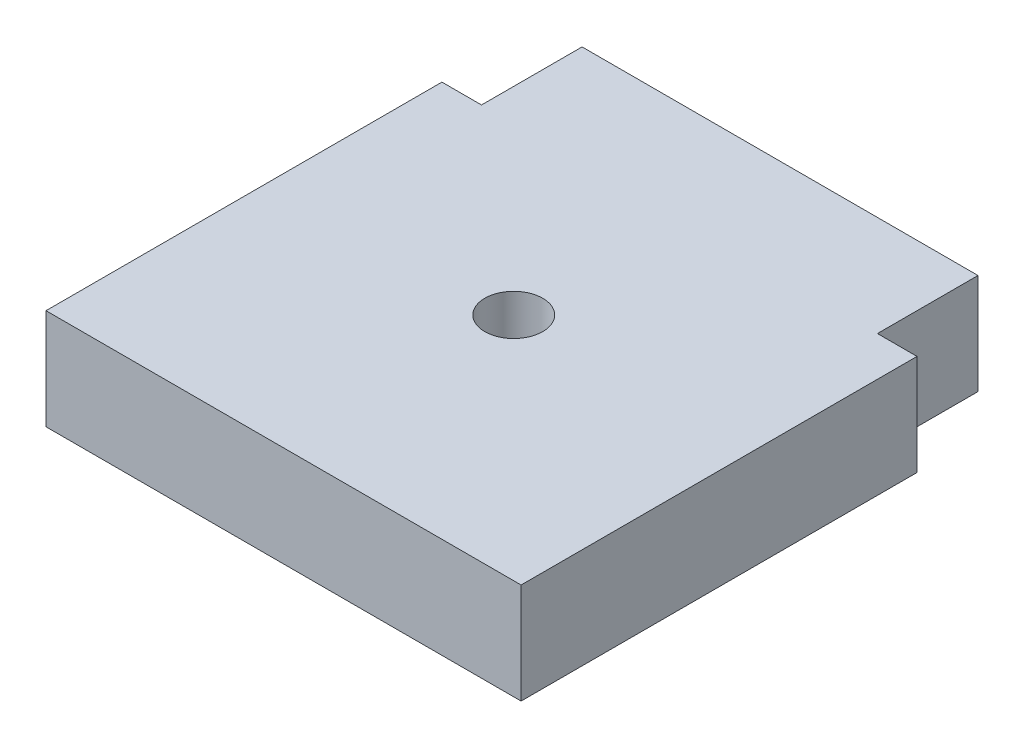
from build123d import *

# Parameters (mm, degrees)
BOSS_EXTRUDE1_DEPTH   = 6.35
F_6_CLEARANCE_HOLE1_D = 3.6576


with BuildPart() as part:
    # Sketch1 → Boss-Extrude1 (new body)
    with BuildSketch(Plane(origin=(0, 0, 0), x_dir=(1, 0, 0), z_dir=(0, 1, 0))):
        Polygon((-12.5, 12.5), (-15, 12.5), (-15, -12.5), (15, -12.5), (15, 12.5), (12.5, 12.5), (12.5, 18.85), (-12.5, 18.85), align=None)
    extrude(amount=BOSS_EXTRUDE1_DEPTH)

    # #6 Clearance Hole1 (through all)
    with Locations(Plane(origin=(0, 6.35, -2.0352), x_dir=(0, 0, 1), z_dir=(0, 1, 0))):
        with Locations((0, 0)):
            Hole(F_6_CLEARANCE_HOLE1_D / 2)


solid = part.part
